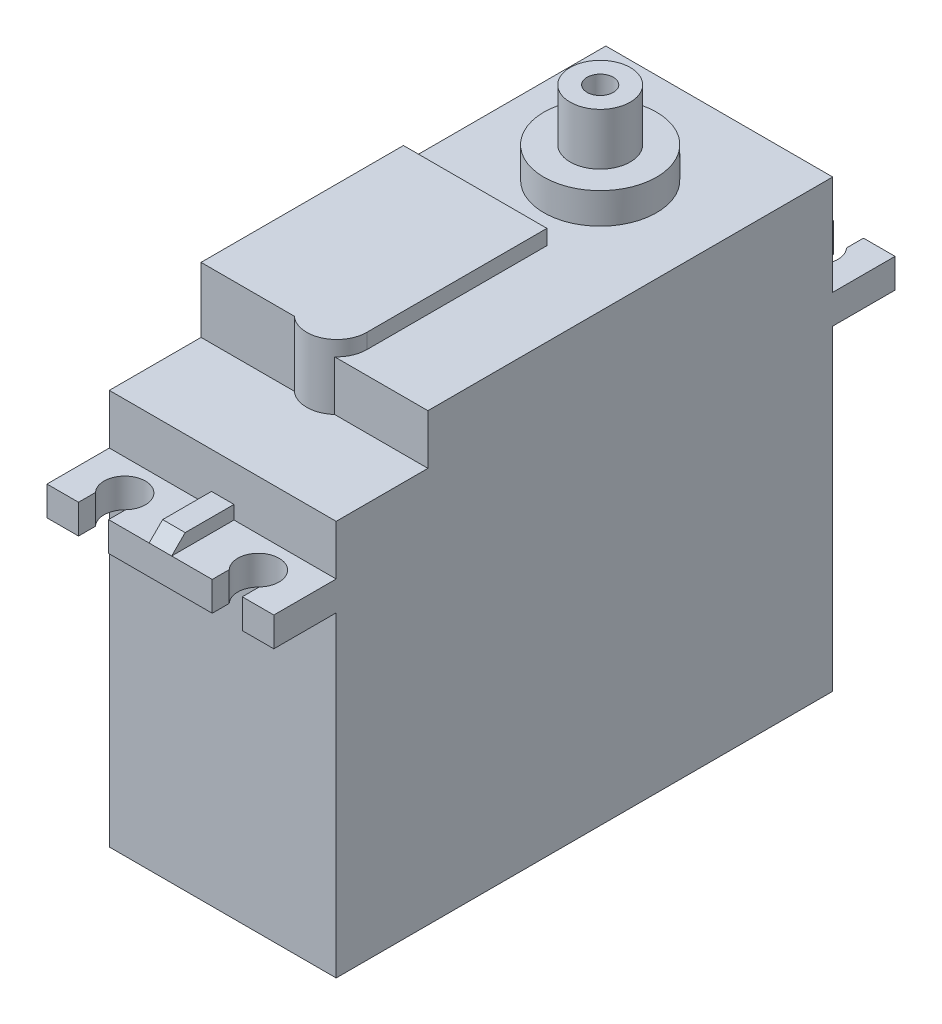
from build123d import *

# Parameters (mm, degrees)
BOSS_EXTRUDE1_DEPTH  = 30.2
CUT_EXTRUDE3_DEPTH   = 6.9
SKETCH10_R           = 7.5
BOSS_EXTRUDE6_DEPTH  = 4.1
SKETCH11_R           = 4
BOSS_EXTRUDE7_DEPTH  = 6.9
BOSS_EXTRUDE8_DEPTH  = 8.9
BOSS_EXTRUDE9_DEPTH  = 2
BOSS_EXTRUDE10_DEPTH = 1.8
CUT_EXTRUDE5_DEPTH   = 4
SKETCH23_R           = 1.75
CUT_EXTRUDE6_DEPTH   = 7


with BuildPart() as part:
    # Sketch1 → Boss-Extrude1 (new body)
    with BuildSketch(Plane(origin=(0, 0, 0), x_dir=(0, 0, -1), z_dir=(1, 0, 0))):
        Polygon((0, 0), (66.1, 0), (66.1, 42.1), (74.4, 42.1), (74.4, 46), (66.1, 46), (66.1, 59.3), (12.213560369, 59.3), (12.213560369, 52.65), (0, 52.65), (0, 46), (-8.3, 46), (-8.3, 42.1), (0, 42.1), align=None)
    extrude(amount=BOSS_EXTRUDE1_DEPTH)

    # Sketch9 → Cut-Extrude3 (cut)
    with BuildSketch(Plane(origin=(0, 46, 0), x_dir=(1, 0, 0), z_dir=(0, 1, 0))):
        with BuildLine():
            Line((22, 74.4), (22, 72.137458609))
            ThreePointArc((22, 72.137458609), (24, 67.5), (26, 72.137458609))
            Line((26, 72.137458609), (26, 74.4))
            Line((26, 74.4), (24, 74.4))
            Line((24, 74.4), (22, 74.4))
        make_face()
        with BuildLine():
            Line((6.2, 74.4), (4.2, 74.4))
            Line((4.2, 74.4), (4.2, 72.137458609))
            ThreePointArc((4.2, 72.137458609), (6.2, 67.5), (8.2, 72.137458609))
            Line((8.2, 72.137458609), (8.2, 74.4))
            Line((8.2, 74.4), (6.2, 74.4))
        make_face()
        with BuildLine():
            Line((24, -8.3), (26, -8.3))
            Line((26, -8.3), (26, -6.037458609))
            ThreePointArc((26, -6.037458609), (24, -1.4), (22, -6.037458609))
            Line((22, -6.037458609), (22, -8.3))
            Line((22, -8.3), (24, -8.3))
        make_face()
        with BuildLine():
            Line((8.2, -8.3), (8.2, -6.037458609))
            ThreePointArc((8.2, -6.037458609), (6.2, -1.4), (4.2, -6.037458609))
            Line((4.2, -6.037458609), (4.2, -8.3))
            Line((4.2, -8.3), (6.2, -8.3))
            Line((6.2, -8.3), (8.2, -8.3))
        make_face()
    extrude(amount=-CUT_EXTRUDE3_DEPTH, mode=Mode.SUBTRACT)

    # Sketch10 → Boss-Extrude6 (add)
    with BuildSketch(Plane(origin=(0, 59.3, 0), x_dir=(1, 0, 0), z_dir=(0, 1, 0))):
        with Locations((15.1, 50.25)):
            Circle(SKETCH10_R)
    extrude(amount=BOSS_EXTRUDE6_DEPTH)

    # Sketch11 → Boss-Extrude7 (add)
    with BuildSketch(Plane(origin=(0, 63.4, 0), x_dir=(1, 0, 0), z_dir=(0, 1, 0))):
        with Locations((15.1, 50.25)):
            Circle(SKETCH11_R)
    extrude(amount=BOSS_EXTRUDE7_DEPTH)

    # Sketch14 → Boss-Extrude8 (add)
    with BuildSketch(Plane(origin=(0, 61.3, 0), x_dir=(1, 0, 0), z_dir=(0, 1, 0))):
        with BuildLine():
            Line((0, 39.156780185), (15.1, 39.156780185))
            Line((15.1, 39.156780185), (19.1, 39.156780185))
            Line((19.1, 39.156780185), (19.1, 15.178872415))
            ThreePointArc((19.1, 15.178872415), (15.1, 11.178872415), (11.1, 15.178872415))
            Line((11.1, 15.178872415), (0, 15.178872415))
            Line((0, 15.178872415), (0, 39.156780185))
        make_face()
    extrude(amount=-BOSS_EXTRUDE8_DEPTH)

    # Sketch17 → Boss-Extrude9 (add)
    with BuildSketch(Plane(origin=(0, 59.3, 0), x_dir=(1, 0, 0), z_dir=(0, 1, 0))):
        Polygon((0, 12.213560369), (15.153721143, 12.213560369), (15.1, 15.178872415), (0, 15.178872415), align=None)
    extrude(amount=BOSS_EXTRUDE9_DEPTH)

    # Sketch18 → Boss-Extrude10 (add)
    with BuildSketch(Plane(origin=(0, 46, 0), x_dir=(1, 0, 0), z_dir=(0, 1, 0))):
        Polygon((15.1, 74.4), (16.6, 74.4), (16.6, 66.1), (13.6, 66.1), (13.6, 74.4), align=None)
        Polygon((13.6, -8.3), (15.1, -8.3), (16.6, -8.3), (16.6, 0), (13.6, 0), align=None)
    extrude(amount=BOSS_EXTRUDE10_DEPTH)

    # Sketch22 → Cut-Extrude5 (cut)
    with BuildSketch(Plane(origin=(16.6, 0, 0), x_dir=(0, 0, -1), z_dir=(1, 0, 0))):
        Polygon((74.4, 46), (72.6, 47.8), (74.4, 47.8), align=None)
        Polygon((-8.3, 47.8), (-8.3, 46), (-6.5, 47.8), align=None)
    extrude(amount=-CUT_EXTRUDE5_DEPTH, mode=Mode.SUBTRACT)

    # Sketch23 → Cut-Extrude6 (cut)
    with BuildSketch(Plane(origin=(0, 70.3, 0), x_dir=(1, 0, 0), z_dir=(0, 1, 0))):
        with Locations((15.1, 50.25)):
            Circle(SKETCH23_R)
    extrude(amount=-CUT_EXTRUDE6_DEPTH, mode=Mode.SUBTRACT)


solid = part.part
